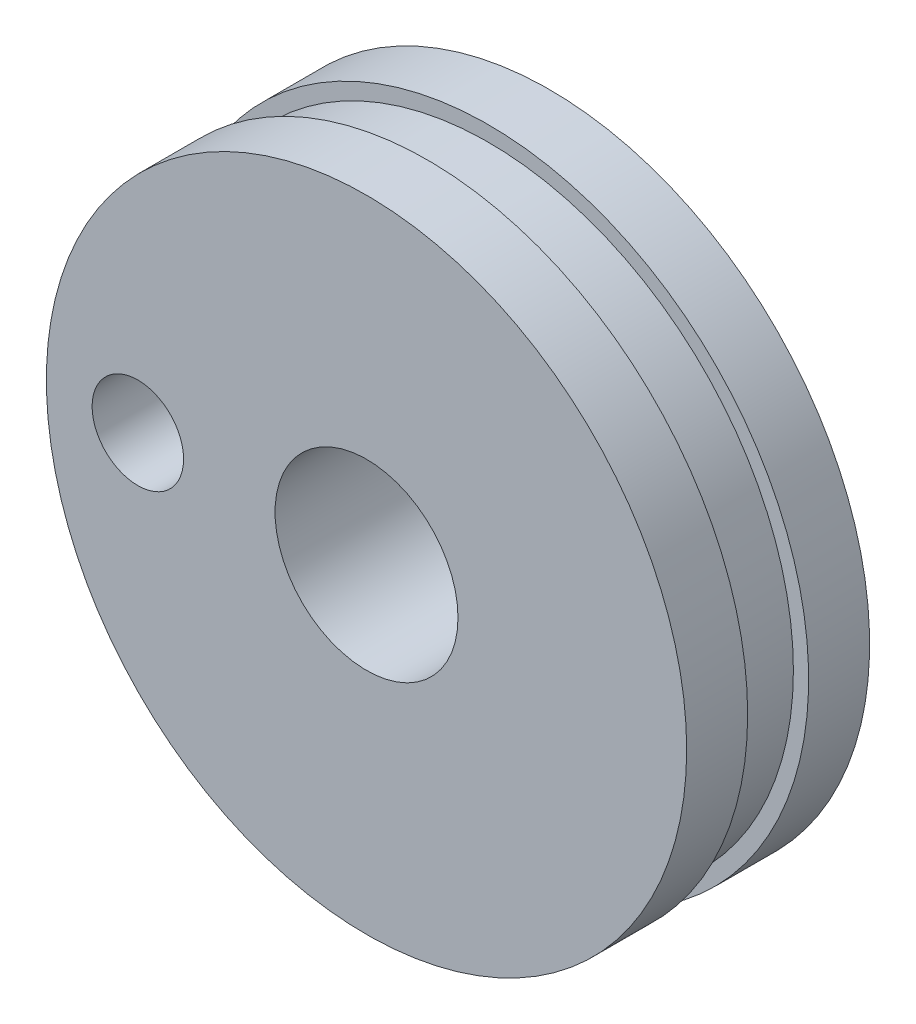
from build123d import *

# Parameters (mm, degrees)
CROQUIS2_R              = 73.5
SALIENTE_EXTRUIR1_DEPTH = 14
CROQUIS6_R              = 70
SALIENTE_EXTRUIR4_DEPTH = 14
CROQUIS8_R              = 73.5
SALIENTE_EXTRUIR5_DEPTH = 14
CROQUIS10_R             = 21
CORTAR_EXTRUIR2_DEPTH   = 84
CROQUIS11_R             = 10.5
CORTAR_EXTRUIR3_DEPTH   = 84


with BuildPart() as part:
    # Croquis2 → Saliente-Extruir1 (new body)
    with BuildSketch(Plane.XY):
        Circle(CROQUIS2_R)
    extrude(amount=SALIENTE_EXTRUIR1_DEPTH)

    # Croquis6 → Saliente-Extruir4 (add)
    with BuildSketch(Plane.XY):
        Circle(CROQUIS6_R)
    extrude(amount=-SALIENTE_EXTRUIR4_DEPTH)

    # Croquis8 → Saliente-Extruir5 (add)
    with BuildSketch(Plane(origin=(0, 0, -14), x_dir=(-1, 0, 0), z_dir=(0, 0, -1))):
        Circle(CROQUIS8_R)
    extrude(amount=SALIENTE_EXTRUIR5_DEPTH)

    # Croquis10 → Cortar-Extruir2 (cut)
    with BuildSketch(Plane.XY.offset(14)):
        Circle(CROQUIS10_R)
    extrude(amount=-CORTAR_EXTRUIR2_DEPTH, mode=Mode.SUBTRACT)

    # Croquis11 → Cortar-Extruir3 (cut)
    with BuildSketch(Plane(origin=(0, 0, -28), x_dir=(-1, 0, 0), z_dir=(0, 0, -1))):
        with Locations((52.5, 0)):
            Circle(CROQUIS11_R)
    extrude(amount=-CORTAR_EXTRUIR3_DEPTH, mode=Mode.SUBTRACT)


solid = part.part
